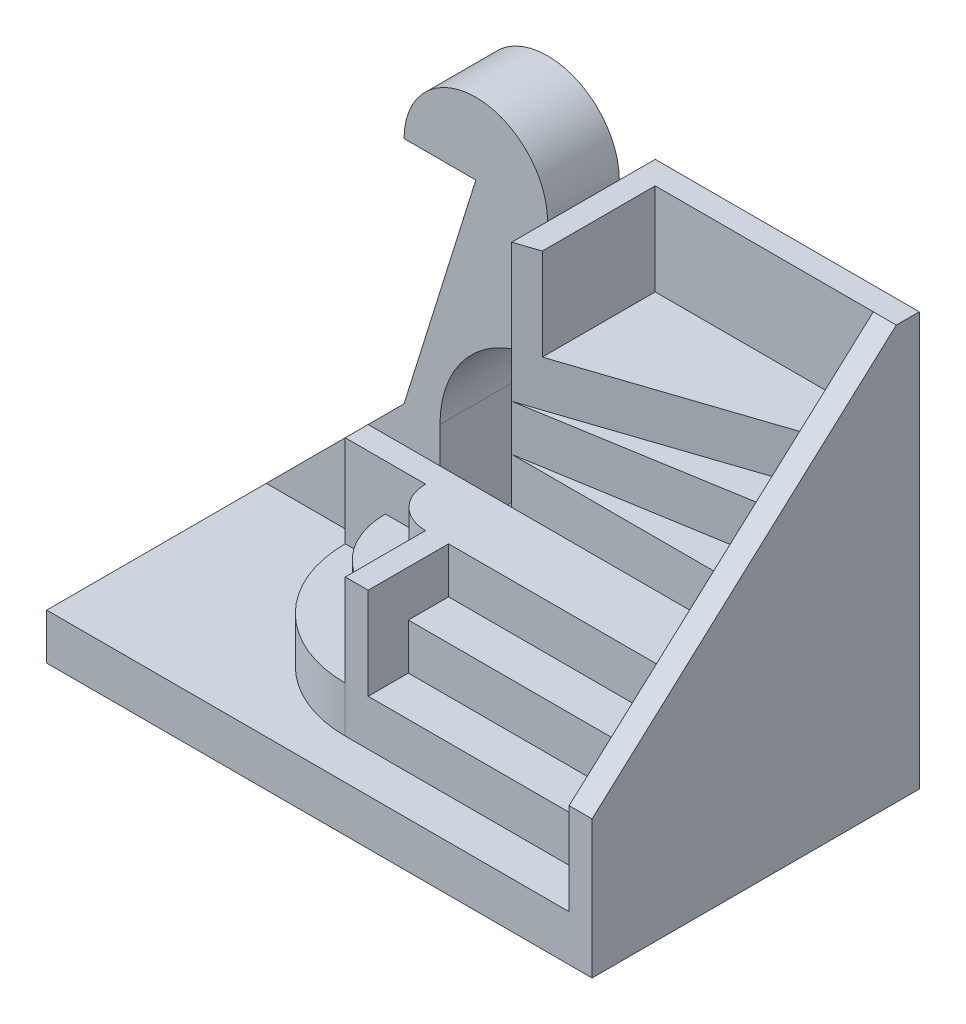
from build123d import *

# Parameters (mm, degrees)
CROQUIS1_W               = 95
CROQUIS1_H               = 57
SALIENTE_EXTRUIR1_DEPTH  = 8
SALIENTE_EXTRUIR2_DEPTH  = 64
SALIENTE_EXTRUIR3_DEPTH  = 24
CROQUIS4_W               = 42
CROQUIS4_H               = 14
CORTAR_EXTRUIR1_DEPTH    = 8
CROQUIS5_W               = 42
CROQUIS5_H               = 7
CORTAR_EXTRUIR2_DEPTH    = 16
CORTAR_EXTRUIR3_DEPTH    = 16
SALIENTE_EXTRUIR6_DEPTH  = 8
SALIENTE_EXTRUIR8_DEPTH  = 16
SALIENTE_EXTRUIR9_DEPTH  = 40
SALIENTE_EXTRUIR10_DEPTH = 24
SALIENTE_EXTRUIR12_DEPTH = 25
CROQUIS13_W              = 49
CROQUIS13_H              = 12.5
SALIENTE_EXTRUIR13_DEPTH = 77.5
CORTAR_EXTRUIR4_DEPTH    = 19.75
CORTAR_EXTRUIR5_REACH    = 52.75


with BuildPart() as part:
    # Croquis1 → Saliente-Extruir1 (new body)
    with BuildSketch(Plane(origin=(0, 0, 0), x_dir=(1, 0, 0), z_dir=(0, 1, 0))):
        with Locations((47.5, 28.5)):
            Rectangle(CROQUIS1_W, CROQUIS1_H)
    extrude(amount=SALIENTE_EXTRUIR1_DEPTH)

    # Croquis2 → Saliente-Extruir2 (add)
    with BuildSketch(Plane(origin=(0, 8, 0), x_dir=(1, 0, 0), z_dir=(0, 1, 0))):
        Polygon((95, 0), (95, 7), (95, 53), (95, 57), (49, 57), (49, 32), (53, 33.826086957), (53, 53), (91, 53), (91, 7), (91, 0), align=None)
    extrude(amount=SALIENTE_EXTRUIR2_DEPTH)

    # Croquis3 → Saliente-Extruir3 (add)
    with BuildSketch(Plane(origin=(0, 8, 0), x_dir=(1, 0, 0), z_dir=(0, 1, 0))):
        with BuildLine():
            Line((45, 7), (91, 7))
            Line((91, 7), (91, 53))
            Line((91, 53), (53, 53))
            Line((53, 53), (53, 33.826086957))
            Line((53, 33.826086957), (49, 32))
            Line((49, 32), (24, 32))
            Line((24, 32), (24, 28))
            ThreePointArc((24, 28), (30.150757595, 13.150757595), (45, 7))
        make_face()
    extrude(amount=SALIENTE_EXTRUIR3_DEPTH)

    # Croquis4 → Cortar-Extruir1 (cut)
    with BuildSketch(Plane(origin=(0, 32, 0), x_dir=(1, 0, 0), z_dir=(0, 1, 0))):
        with BuildLine():
            ThreePointArc((38, 28), (40.050252532, 23.050252532), (45, 21))
            Line((45, 21), (45, 7))
            ThreePointArc((45, 7), (30.150757595, 13.150757595), (24, 28))
            Line((24, 28), (38, 28))
        make_face()
        with Locations((70, 14)):
            Rectangle(CROQUIS4_W, CROQUIS4_H)
    extrude(amount=-CORTAR_EXTRUIR1_DEPTH, mode=Mode.SUBTRACT)

    # Croquis5 → Cortar-Extruir2 (cut)
    with BuildSketch(Plane(origin=(0, 32, 0), x_dir=(1, 0, 0), z_dir=(0, 1, 0))):
        with BuildLine():
            ThreePointArc((45, 14), (35.100505063, 18.100505063), (31, 28))
            Line((31, 28), (24, 28))
            ThreePointArc((24, 28), (30.150757595, 13.150757595), (45, 7))
            Line((45, 7), (45, 14))
        make_face()
        with Locations((70, 10.5)):
            Rectangle(CROQUIS5_W, CROQUIS5_H)
    extrude(amount=-CORTAR_EXTRUIR2_DEPTH, mode=Mode.SUBTRACT)

    # Croquis6 → Cortar-Extruir3 (cut)
    with BuildSketch(Plane(origin=(95, 0, 0), x_dir=(0, 0, -1), z_dir=(1, 0, 0))):
        Polygon((0, 72), (0, 24), (53, 72), align=None)
    extrude(amount=-CORTAR_EXTRUIR3_DEPTH, mode=Mode.SUBTRACT)



with BuildPart() as body_2:
    # Croquis7 → Saliente-Extruir6 (new body)
    with BuildSketch(Plane(origin=(0, 32, 0), x_dir=(1, 0, 0), z_dir=(0, 1, 0))):
        Polygon((49, 32), (91, 32), (91, 39), align=None)
    extrude(amount=SALIENTE_EXTRUIR6_DEPTH)


with BuildPart() as body_3:
    # Croquis9 → Saliente-Extruir8 (new body)
    with BuildSketch(Plane(origin=(0, 32, 0), x_dir=(1, 0, 0), z_dir=(0, 1, 0))):
        Polygon((91, 39), (91, 46), (49, 32), align=None)
    extrude(amount=SALIENTE_EXTRUIR8_DEPTH)


with BuildPart() as part_1:
    add(part.part)

    add(body_2.part)  # Saliente-Extruir9 merges body 2

    add(body_3.part)  # Saliente-Extruir9 merges body 3
    # Croquis10 → Saliente-Extruir9 (add)
    with BuildSketch(Plane(origin=(0, 32, 0), x_dir=(1, 0, 0), z_dir=(0, 1, 0))):
        Polygon((49, 32), (53, 33.826086957), (53, 33.333333333), align=None)
    extrude(amount=SALIENTE_EXTRUIR9_DEPTH)

    # Croquis11 → Saliente-Extruir10 (add)
    with BuildSketch(Plane(origin=(0, 32, 0), x_dir=(1, 0, 0), z_dir=(0, 1, 0))):
        Polygon((53, 53), (53, 33.333333333), (91, 46), (91, 53), align=None)
    extrude(amount=SALIENTE_EXTRUIR10_DEPTH)

    # Croquis12 → Saliente-Extruir12 (add)
    with BuildSketch(Plane(origin=(0, 0, -32), x_dir=(-1, 0, 0), z_dir=(0, 0, -1))):
        Polygon((-49, 32), (-49, 8), (-24, 8), align=None)
    extrude(amount=SALIENTE_EXTRUIR12_DEPTH)

    # Croquis13 → Saliente-Extruir13 (add)
    with BuildSketch(Plane(origin=(0, 8, 0), x_dir=(1, 0, 0), z_dir=(0, 1, 0))):
        with Locations((24.5, 44.5)):
            Rectangle(CROQUIS13_W, CROQUIS13_H)
    extrude(amount=SALIENTE_EXTRUIR13_DEPTH)

    # Croquis14 → Cortar-Extruir4 (cut, through all)
    with BuildSketch(Plane.XY.offset(-38.25)):
        with BuildLine():
            Line((24, 32), (0, 8))
            Line((0, 8), (0, 85.5))
            Line((0, 85.5), (49, 85.5))
            Line((49, 85.5), (49, 72))
            ThreePointArc((49, 72), (36.5, 84.5), (24, 72))
            Line((24, 72), (36.5, 72))
            Line((36.5, 72), (24, 32))
        make_face()
        with BuildLine():
            Line((49, 50.75), (49, 32))
            Line((49, 32), (30.25, 32))
            ThreePointArc((30.25, 32), (35.741747853, 45.258252147), (49, 50.75))
        make_face()
    extrude(amount=-CORTAR_EXTRUIR4_DEPTH, mode=Mode.SUBTRACT)

    # Croquis15 → Cortar-Extruir5 (cut, up to next)
    with BuildSketch(Plane(origin=(0, 0, -50.75), x_dir=(-1, 0, 0), z_dir=(0, 0, -1)), mode=Mode.PRIVATE) as cortar_extruir5_sk1:
        Polygon((-30.25, 32), (-49, 32), (-30.25, 14), align=None)
    cortar_extruir5_tool1 = extrude(cortar_extruir5_sk1.sketch, amount=-CORTAR_EXTRUIR5_REACH, mode=Mode.PRIVATE) & part_1.part
    add(cortar_extruir5_tool1.solids().sort_by_distance((36.5, 26, -50.75))[0], mode=Mode.SUBTRACT)


solid = part_1.part
